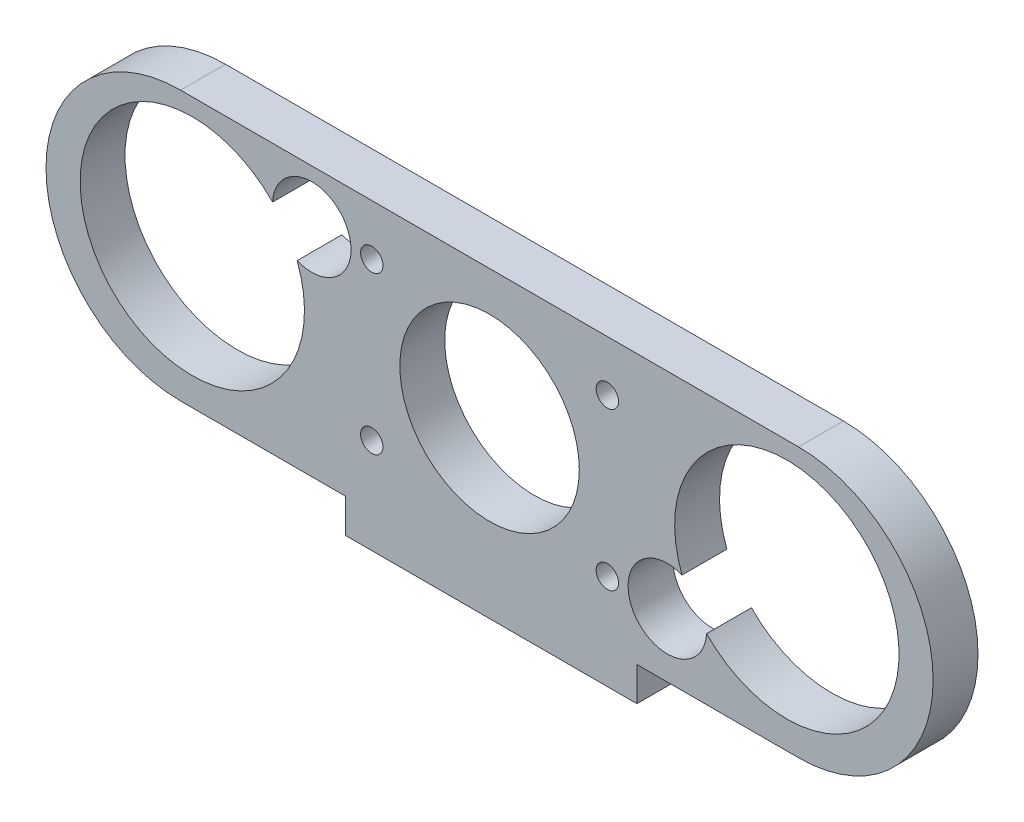
from build123d import *

# Parameters (mm, degrees)
SKETCH2_R           = 1
SKETCH2_R_2         = 8
BOSS_EXTRUDE2_DEPTH = 4


with BuildPart() as part:
    # Sketch2 → Boss-Extrude2 (new body)
    with BuildSketch(Plane.XY):
        with BuildLine():
            Line((-18.567970323, 27.379059863), (36.515267991, 27.379059863))
            ThreePointArc((36.515267991, 27.379059863), (48.515267991, 15.379059863), (36.515267991, 3.379059863))
            Line((36.515267991, 3.379059863), (22.110149126, 3.379059863))
            Line((22.110149126, 3.379059863), (22.110149126, 0.351018879))
            Line((22.110149126, 0.351018879), (-3.889850874, 0.351018879))
            Line((-3.889850874, 0.351018879), (-3.889850874, 3.379059863))
            Line((-3.889850874, 3.379059863), (-18.567970323, 3.379059863))
            ThreePointArc((-18.567970323, 3.379059863), (-30.567970323, 15.379059863), (-18.567970323, 27.379059863))
        make_face()
        with Locations((-1.526351166, 22.851018879)):
            Circle(SKETCH2_R, mode=Mode.SUBTRACT)
        with Locations((19.473648834, 22.851018879)):
            Circle(SKETCH2_R, mode=Mode.SUBTRACT)
        with Locations((-1.526351166, 8.851018879)):
            Circle(SKETCH2_R, mode=Mode.SUBTRACT)
        with Locations((19.473648834, 8.851018879)):
            Circle(SKETCH2_R, mode=Mode.SUBTRACT)
        with Locations((8.973648834, 15.851018879)):
            Circle(SKETCH2_R_2, mode=Mode.SUBTRACT)
        with BuildLine():
            ThreePointArc((-10.371103668, 22.836892714), (-25.952222618, 10.465418608), (-8.181666286, 19.411477345))
            ThreePointArc((-8.181666286, 19.411477345), (-3.926588869, 24.543637074), (-10.371103668, 22.836892714))
        make_face(mode=Mode.SUBTRACT)
        with BuildLine():
            ThreePointArc((28.318401336, 8.865145043), (43.899520286, 21.236619149), (26.128963954, 12.290560412))
            ThreePointArc((26.128963954, 12.290560412), (21.873886537, 7.158400683), (28.318401336, 8.865145043))
        make_face(mode=Mode.SUBTRACT)
    extrude(amount=BOSS_EXTRUDE2_DEPTH)


solid = part.part
